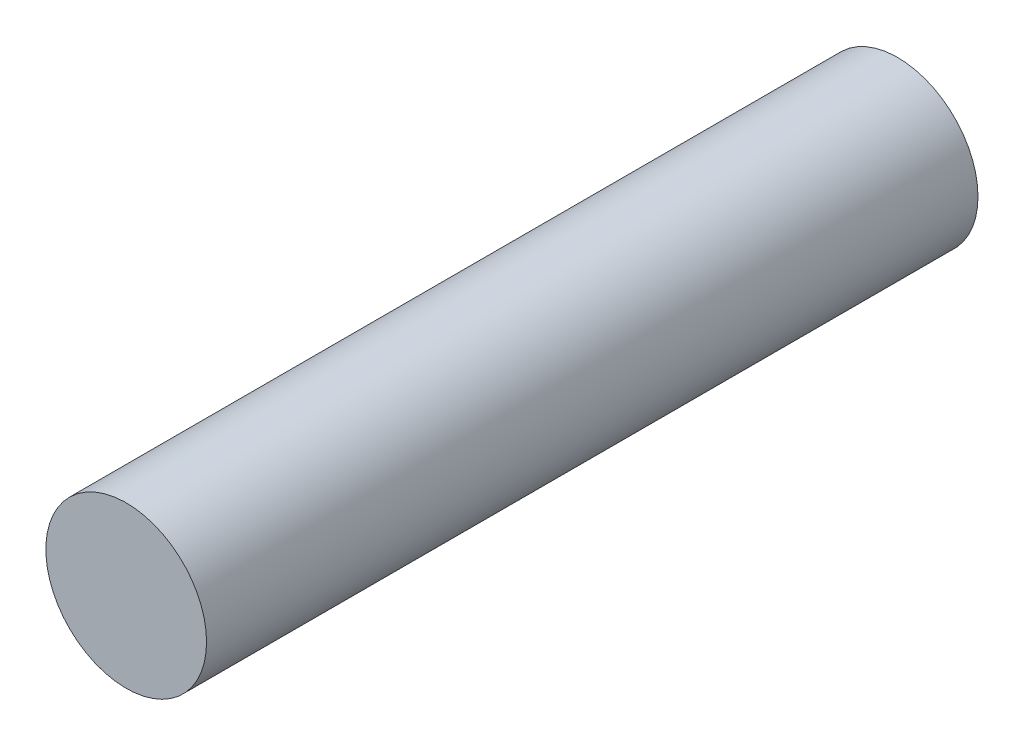
from build123d import *

# Parameters (mm, degrees)
SKETCH1_R           = 2.5
BOSS_EXTRUDE1_DEPTH = 24


with BuildPart() as part:
    # Sketch1 → Boss-Extrude1 (new body)
    with BuildSketch(Plane.XY):
        Circle(SKETCH1_R)
    extrude(amount=BOSS_EXTRUDE1_DEPTH)


solid = part.part
